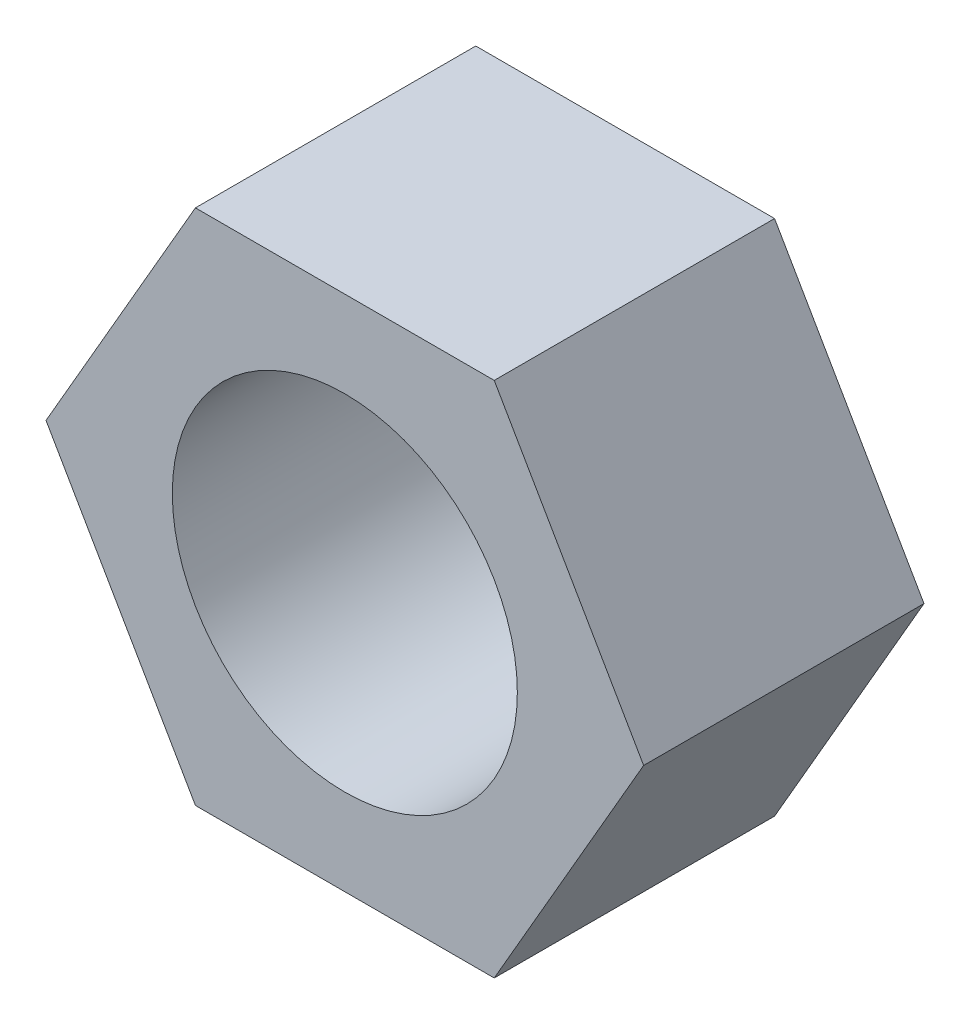
from build123d import *

# Parameters (mm, degrees)
ESBO_O1_R                = 4
RESSALTO_EXTRUS_O1_DEPTH = 6.5


with BuildPart() as part:
    # Esboço1 → Ressalto-extrusão1 (new body)
    with BuildSketch(Plane.XY):
        Polygon((6.92820323, 0), (3.464101615, 6), (-3.464101615, 6), (-6.92820323, 0), (-3.464101615, -6), (3.464101615, -6), align=None)
        Circle(ESBO_O1_R, mode=Mode.SUBTRACT)
    extrude(amount=RESSALTO_EXTRUS_O1_DEPTH)


solid = part.part
